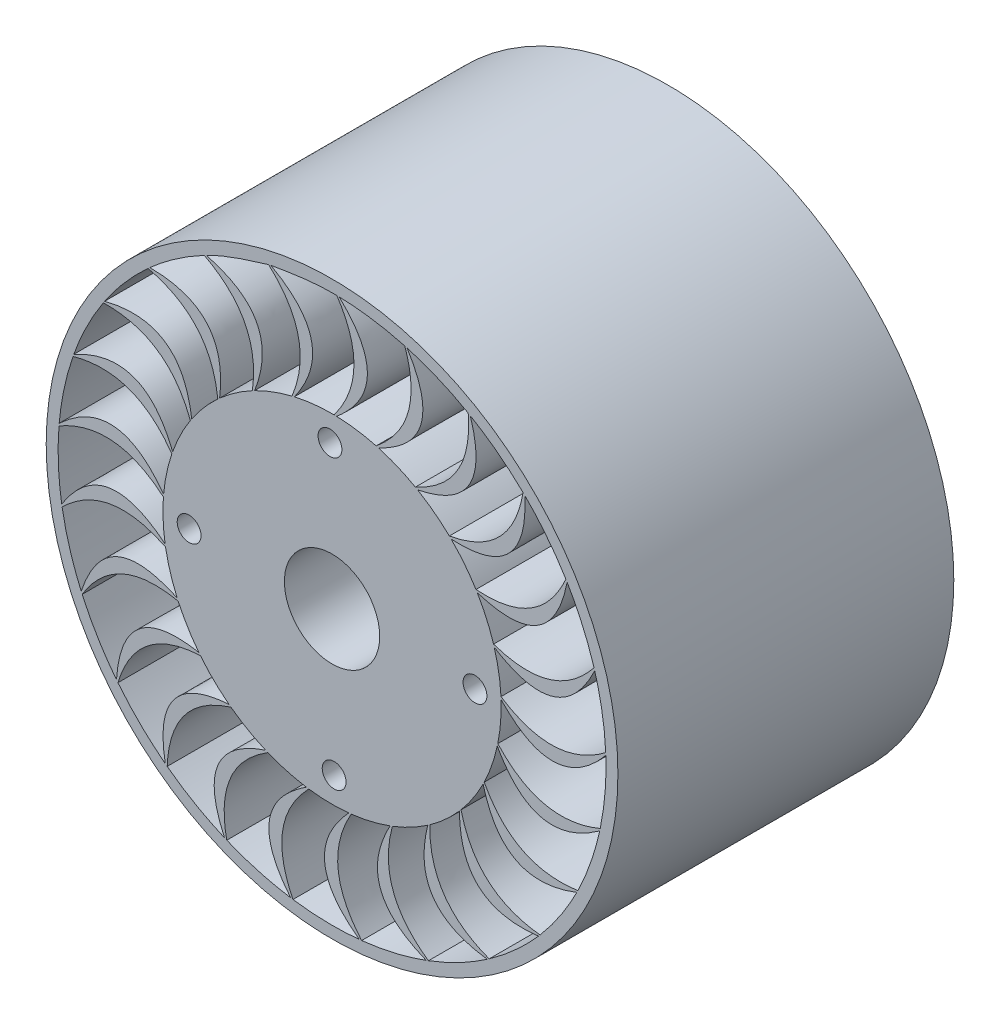
from build123d import *

# Parameters (mm, degrees)
SKETCH1_R           = 70
SKETCH1_R_2         = 50
BOSS_EXTRUDE1_DEPTH = 30
SKETCH2_R           = 70
SKETCH2_R_2         = 34
BOSS_EXTRUDE2_DEPTH = 81
SKETCH3_R           = 70
SKETCH3_R_2         = 20
BOSS_EXTRUDE3_DEPTH = 30
SKETCH5_R           = 120
SKETCH5_R_2         = 70
BOSS_EXTRUDE4_DEPTH = 141
SKETCH6_R           = 5
CUT_EXTRUDE1_DEPTH  = 142.0000001


with BuildPart() as part:
    # Sketch1 → Boss-Extrude1 (new body)
    with BuildSketch(Plane.XY):
        Circle(SKETCH1_R)
        Circle(SKETCH1_R_2, mode=Mode.SUBTRACT)
    extrude(amount=BOSS_EXTRUDE1_DEPTH)

    # Sketch2 → Boss-Extrude2 (add)
    with BuildSketch(Plane.XY.offset(30)):
        Circle(SKETCH2_R)
        Circle(SKETCH2_R_2, mode=Mode.SUBTRACT)
    extrude(amount=BOSS_EXTRUDE2_DEPTH)

    # Sketch3 → Boss-Extrude3 (add)
    with BuildSketch(Plane.XY.offset(111)):
        Circle(SKETCH3_R)
        Circle(SKETCH3_R_2, mode=Mode.SUBTRACT)
    extrude(amount=BOSS_EXTRUDE3_DEPTH)

    # Sketch5 → Boss-Extrude4 (add)
    with BuildSketch(Plane.XY.offset(141)):
        Circle(SKETCH5_R)
        Circle(SKETCH5_R_2, mode=Mode.SUBTRACT)
        with BuildLine():
            add(Edge.make_bspline(
                [(3.010356442, 114.960592179), (27.186039346, 92.132028613), (1.880486429, 70.975092609)],
                knots=[0, 0, 0, 1, 1, 1], degree=2))
            add(Edge.make_bspline(
                [(1.880486429, 70.975092609), (7.482108789, 70.809428101), (13.106315909, 70.025111339), (18.509578891, 68.548490058)],
                knots=[0.04013797, 0.04013797, 0.04013797, 0.04013797, 0.078021655, 0.078021655, 0.078021655, 0.078021655], degree=3))
            add(Edge.make_bspline(
                [(30.542982673, 110.872116465), (39.387805802, 85.35679232), (18.509578891, 68.548490058)],
                knots=[0, 0, 0, 1, 1, 1], degree=2))
            add(Edge.make_bspline(
                [(3.010356442, 114.960592179), (12.287578337, 114.69195374), (21.602560741, 113.35448348), (30.542982673, 110.872116465)],
                knots=[0.040055567, 0.040055567, 0.040055567, 0.040055567, 0.07872198, 0.07872198, 0.07872198, 0.07872198], degree=3))
        make_face(mode=Mode.SUBTRACT)
        with BuildLine():
            add(Edge.make_bspline(
                [(2.010644574, 114.984595961), (16.922994403, 92.47050071), (0.880750175, 70.998058277)],
                knots=[0, 0, 0, 1, 1, 1], degree=2))
            add(Edge.make_bspline(
                [(-15.829380282, 69.212937518), (-7.517567155, 71.135198843), (0.880750175, 70.998058277)],
                knots=[0, 0, 0, 0.037883687, 0.037883687, 0.037883687], degree=2))
            add(Edge.make_bspline(
                [(-25.673756139, 112.097538982), (3.419636128, 95.998424573), (-15.829380282, 69.212937518)],
                knots=[0, 0, 0, 1, 1, 1], degree=2))
            add(Edge.make_bspline(
                [(-25.673756139, 112.097538982), (-16.468268012, 113.6256958), (-7.262779885, 115.153852619), (2.010644574, 114.984595961)],
                knots=[0, 0, 0, 0, 0.038666414, 0.038666414, 0.038666414, 0.038666414], degree=3))
        make_face(mode=Mode.SUBTRACT)
        with BuildLine():
            add(Edge.make_bspline(
                [(31.505317256, 110.600248574), (49.244243728, 82.476638458), (19.472195263, 68.277621602)],
                knots=[0, 0, 0, 1, 1, 1], degree=2))
            add(Edge.make_bspline(
                [(19.472195263, 68.277621602), (24.856925464, 66.724358238), (30.109025893, 64.5670177), (34.975382691, 61.791768106)],
                knots=[0.027314642, 0.027314642, 0.027314642, 0.027314642, 0.486342697, 0.486342697, 0.486342697, 0.486342697], degree=3))
            add(Edge.make_bspline(
                [(57.156192841, 99.793134132), (59.377736504, 72.879802749), (34.975382691, 61.791768106)],
                knots=[0, 0, 0, 1, 1, 1], degree=2))
            add(Edge.make_bspline(
                [(31.505317256, 110.600248574), (40.42406203, 108.038799553), (49.113985563, 104.421038961), (57.156192841, 99.793134132)],
                knots=[0.080111133, 0.080111133, 0.080111133, 0.080111133, 0.118777546, 0.118777546, 0.118777546, 0.118777546], degree=3))
        make_face(mode=Mode.SUBTRACT)
        with BuildLine():
            add(Edge.make_bspline(
                [(58.020683118, 99.290484592), (68.208251169, 67.638937781), (35.840394454, 61.290016523)],
                knots=[0, 0, 0, 1, 1, 1], degree=2))
            add(Edge.make_bspline(
                [(35.840394454, 61.290016523), (40.667339603, 58.445243533), (45.217702636, 55.050026808), (49.243554567, 51.152442108)],
                knots=[0.513657329, 0.513657329, 0.513657329, 0.513657329, 0.972685383, 0.972685383, 0.972685383, 0.972685383], degree=3))
            add(Edge.make_bspline(
                [(80.178069207, 82.443782168), (75.636745646, 55.823507137), (49.243554567, 51.152442108)],
                knots=[0, 0, 0, 1, 1, 1], degree=2))
            add(Edge.make_bspline(
                [(58.020683118, 99.290484592), (66.022220381, 94.591570991), (73.539435738, 88.926309934), (80.178069207, 82.443782168)],
                knots=[0.120166699, 0.120166699, 0.120166699, 0.120166699, 0.158833112, 0.158833112, 0.158833112, 0.158833112], degree=3))
        make_face(mode=Mode.SUBTRACT)
        with BuildLine():
            add(Edge.make_bspline(
                [(80.890396075, 81.741934298), (82.886483337, 48.551233884), (49.95660985, 50.451334297)],
                knots=[0, 0, 0, 1, 1, 1], degree=2))
            add(Edge.make_bspline(
                [(49.95660985, 50.451334297), (53.924021721, 46.495976763), (57.490074061, 42.075360103), (60.417572803, 37.299020048)],
                knots=[0.159954411, 0.159954411, 0.159954411, 0.159954411, 0.197838097, 0.197838097, 0.197838097, 0.197838097], degree=3))
            add(Edge.make_bspline(
                [(98.162062611, 59.914184164), (87.143219886, 35.259615268), (60.417572803, 37.299020048)],
                knots=[0, 0, 0, 1, 1, 1], degree=2))
            add(Edge.make_bspline(
                [(80.890396075, 81.741934298), (87.471978013, 75.200745013), (93.344133117, 67.844012423), (98.162062611, 59.914184164)],
                knots=[0.160222265, 0.160222265, 0.160222265, 0.160222265, 0.198888678, 0.198888678, 0.198888678, 0.198888678], degree=3))
        make_face(mode=Mode.SUBTRACT)
        with BuildLine():
            add(Edge.make_bspline(
                [(98.677467953, 59.057237647), (92.356652922, 26.412877403), (60.933867721, 36.44260919)],
                knots=[0, 0, 0, 1, 1, 1], degree=2))
            add(Edge.make_bspline(
                [(60.933867721, 36.44260919), (63.793312468, 31.624291819), (66.147646288, 26.456264684), (67.795332741, 21.101963382)],
                knots=[0.20009238, 0.20009238, 0.20009238, 0.20009238, 0.237976065, 0.237976065, 0.237976065, 0.237976065], degree=3))
            add(Edge.make_bspline(
                [(109.978172606, 33.619957619), (93.174165131, 12.480232096), (67.795332741, 21.101963382)],
                knots=[0, 0, 0, 1, 1, 1], degree=2))
            add(Edge.make_bspline(
                [(98.677467953, 59.057237647), (103.425549766, 51.084778989), (107.283675322, 42.498826084), (109.978172606, 33.619957619)],
                knots=[0.200277831, 0.200277831, 0.200277831, 0.200277831, 0.238944244, 0.238944244, 0.238944244, 0.238944244], degree=3))
        make_face(mode=Mode.SUBTRACT)
        with BuildLine():
            add(Edge.make_bspline(
                [(110.264271608, 32.661757556), (96.02371434, 2.614902696), (68.082426584, 20.144060921)],
                knots=[0, 0, 0, 1, 1, 1], degree=2))
            add(Edge.make_bspline(
                [(68.082426584, 20.144060921), (69.653775512, 14.765995138), (70.648902028, 9.174841436), (70.913262588, 3.578992749)],
                knots=[0.240230348, 0.240230348, 0.240230348, 0.240230348, 0.278114034, 0.278114034, 0.278114034, 0.278114034], degree=3))
            add(Edge.make_bspline(
                [(114.883949544, 5.213265492), (93.35063491, -11.083329958), (70.913262588, 3.578992749)],
                knots=[0, 0, 0, 1, 1, 1], degree=2))
            add(Edge.make_bspline(
                [(110.264271608, 32.661757556), (112.880513856, 23.758968418), (114.482189644, 14.483282202), (114.883949544, 5.213265492)],
                knots=[0.240333397, 0.240333397, 0.240333397, 0.240333397, 0.278999811, 0.278999811, 0.278999811, 0.278999811], degree=3))
        make_face(mode=Mode.SUBTRACT)
        with BuildLine():
            add(Edge.make_bspline(
                [(114.922765555, 4.214019117), (93.657252635, -21.347375965), (70.953116196, 2.579787219)],
                knots=[0, 0, 0, 1, 1, 1], degree=2))
            add(Edge.make_bspline(
                [(70.953116196, 2.579787219), (71.137627832, -3.020095492), (70.711027141, -8.683070558), (69.575451347, -14.168859161)],
                knots=[0.280368316, 0.280368316, 0.280368316, 0.280368316, 0.318252002, 0.318252002, 0.318252002, 0.318252002], degree=3))
            add(Edge.make_bspline(
                [(112.57114542, -23.520995279), (87.661540978, -33.950485629), (69.575451347, -14.168859161)],
                knots=[0, 0, 0, 1, 1, 1], degree=2))
            add(Edge.make_bspline(
                [(114.922765555, 4.214019117), (115.242780116, -5.059705519), (114.487366955, -14.442299566), (112.57114542, -23.520995279)],
                knots=[0.280388964, 0.280388964, 0.280388964, 0.280388964, 0.319055377, 0.319055377, 0.319055377, 0.319055377], degree=3))
        make_face(mode=Mode.SUBTRACT)
        with BuildLine():
            add(Edge.make_bspline(
                [(112.360239486, -24.498501641), (85.405961299, -43.968320484), (69.365560569, -15.146584001)],
                knots=[0, 0, 0, 1, 1, 1], degree=2))
            add(Edge.make_bspline(
                [(69.365560569, -15.146584001), (68.151641236, -20.61642228), (66.330118358, -25.995393291), (63.865958616, -31.026429541)],
                knots=[0.320506285, 0.320506285, 0.320506285, 0.320506285, 0.35838997, 0.35838997, 0.35838997, 0.35838997], degree=3))
            add(Edge.make_bspline(
                [(103.18508222, -50.777345413), (76.464350029, -54.684407427), (63.865958616, -31.026429541)],
                knots=[0, 0, 0, 1, 1, 1], degree=2))
            add(Edge.make_bspline(
                [(112.360239486, -24.498501641), (110.363918667, -33.560459549), (107.298881945, -42.460418538), (103.18508222, -50.777345413)],
                knots=[0.32044453, 0.32044453, 0.32044453, 0.32044453, 0.359110943, 0.359110943, 0.359110943, 0.359110943], degree=3))
        make_face(mode=Mode.SUBTRACT)
        with BuildLine():
            add(Edge.make_bspline(
                [(102.737706338, -51.671691442), (71.788299315, -63.826573723), (63.419511664, -31.921239643)],
                knots=[0, 0, 0, 1, 1, 1], degree=2))
            add(Edge.make_bspline(
                [(63.419511664, -31.921239643), (60.883436374, -36.917343432), (57.781444292, -41.674329859), (54.143532823, -45.934495245)],
                knots=[0.360644253, 0.360644253, 0.360644253, 0.360644253, 0.398527939, 0.398527939, 0.398527939, 0.398527939], degree=3))
            add(Edge.make_bspline(
                [(87.315520817, -74.843168188), (60.462622752, -71.982306791), (54.143532823, -45.934495245)],
                knots=[0, 0, 0, 1, 1, 1], degree=2))
            add(Edge.make_bspline(
                [(102.737706338, -51.671691442), (98.550486319, -59.95248648), (93.368413565, -67.810593254), (87.315520817, -74.843168188)],
                knots=[0.360500096, 0.360500096, 0.360500096, 0.360500096, 0.399166509, 0.399166509, 0.399166509, 0.399166509], degree=3))
        make_face(mode=Mode.SUBTRACT)
        with BuildLine():
            add(Edge.make_bspline(
                [(86.659785257, -75.598158834), (53.659914465, -79.674368597), (53.4885816, -46.6901664)],
                knots=[0, 0, 0, 1, 1, 1], degree=2))
            add(Edge.make_bspline(
                [(53.4885816, -46.6901664), (49.789701291, -50.898612124), (45.602149577, -54.734715014), (41.019069737, -57.956327678)],
                knots=[0.400782221, 0.400782221, 0.400782221, 0.400782221, 0.438665907, 0.438665907, 0.438665907, 0.438665907], degree=3))
            add(Edge.make_bspline(
                [(65.959604117, -94.206319452), (40.661806522, -84.757293087), (41.019069737, -57.956327678)],
                knots=[0, 0, 0, 1, 1, 1], degree=2))
            add(Edge.make_bspline(
                [(86.659785257, -75.598158834), (80.544764471, -82.577478195), (73.571264376, -88.899979006), (65.959604117, -94.206319452)],
                knots=[0.400555662, 0.400555662, 0.400555662, 0.400555662, 0.439222075, 0.439222075, 0.439222075, 0.439222075], degree=3))
        make_face(mode=Mode.SUBTRACT)
        with BuildLine():
            add(Edge.make_bspline(
                [(65.136711157, -94.774515877), (32.159879842, -90.51592987), (40.196767236, -58.525378288)],
                knots=[0, 0, 0, 1, 1, 1], degree=2))
            add(Edge.make_bspline(
                [(40.196767236, -58.525378288), (35.567496163, -61.681733823), (30.557504091, -64.355916724), (25.317227642, -66.336550894)],
                knots=[0.44092019, 0.44092019, 0.44092019, 0.44092019, 0.478803876, 0.478803876, 0.478803876, 0.478803876], degree=3))
            add(Edge.make_bspline(
                [(40.459202907, -107.650141199), (18.306059444, -92.206666943), (25.317227642, -66.336550894)],
                knots=[0, 0, 0, 1, 1, 1], degree=2))
            add(Edge.make_bspline(
                [(65.136711157, -94.774515877), (57.478118849, -100.013823256), (49.151362069, -104.403452126), (40.459202907, -107.650141199)],
                knots=[0.440611228, 0.440611228, 0.440611228, 0.440611228, 0.479277641, 0.479277641, 0.479277641, 0.479277641], degree=3))
        make_face(mode=Mode.SUBTRACT)
        with BuildLine():
            add(Edge.make_bspline(
                [(39.520857939, -107.99584153), (8.639121693, -95.670042375), (24.379242154, -66.683225417)],
                knots=[0, 0, 0, 1, 1, 1], degree=2))
            add(Edge.make_bspline(
                [(24.379242154, -66.683225417), (19.110454442, -68.589165338), (13.592818241, -69.933399496), (8.024611024, -70.548604649)],
                knots=[0.481058158, 0.481058158, 0.481058158, 0.481058158, 0.518941844, 0.518941844, 0.518941844, 0.518941844], degree=3))
            add(Edge.make_bspline(
                [(12.416601181, -114.329908664), (-5.199924674, -93.862356802), (8.024611024, -70.548604649)],
                knots=[0, 0, 0, 1, 1, 1], degree=2))
            add(Edge.make_bspline(
                [(39.520857939, -107.99584153), (30.799911632, -111.165931976), (21.643098918, -113.34687238), (12.416601181, -114.329908664)],
                knots=[0.480666794, 0.480666794, 0.480666794, 0.480666794, 0.519333207, 0.519333207, 0.519333207, 0.519333207], degree=3))
        make_face(mode=Mode.SUBTRACT)
        with BuildLine():
            add(Edge.make_bspline(
                [(11.421763868, -114.431391279), (-15.424464244, -94.812854268), (7.029879627, -70.651120249)],
                knots=[0, 0, 0, 1, 1, 1], degree=2))
            add(Edge.make_bspline(
                [(7.029879627, -70.651120249), (1.452632586, -71.186887328), (-4.225954335, -71.11670922), (-9.772221418, -70.327830114)],
                knots=[0.521196127, 0.521196127, 0.521196127, 0.521196127, 0.559079812, 0.559079812, 0.559079812, 0.559079812], degree=3))
            add(Edge.make_bspline(
                [(-16.406181263, -113.825907492), (-28.3791784, -89.620329582), (-9.772221418, -70.327830114)],
                knots=[0, 0, 0, 1, 1, 1], degree=2))
            add(Edge.make_bspline(
                [(11.421763868, -114.431391279), (2.18643269, -115.333076352), (-7.225079736, -115.168291782), (-16.406181263, -113.825907492)],
                knots=[0.52072236, 0.52072236, 0.52072236, 0.52072236, 0.559388773, 0.559388773, 0.559388773, 0.559388773], degree=3))
        make_face(mode=Mode.SUBTRACT)
        with BuildLine():
            add(Edge.make_bspline(
                [(-17.395001632, -113.676795865), (-38.518874366, -87.99822583), (-10.761196091, -70.179745359)],
                knots=[0, 0, 0, 1, 1, 1], degree=2))
            add(Edge.make_bspline(
                [(-10.761196091, -70.179745359), (-16.296463442, -69.311674615), (-21.779192573, -67.831473417), (-26.955029248, -65.688099366)],
                knots=[0.561334095, 0.561334095, 0.561334095, 0.561334095, 0.599217781, 0.599217781, 0.599217781, 0.599217781], degree=3))
            add(Edge.make_bspline(
                [(-44.198103, -106.16980593), (-49.775263977, -79.747127454), (-26.955029248, -65.688099366)],
                knots=[0, 0, 0, 1, 1, 1], degree=2))
            add(Edge.make_bspline(
                [(-17.395001632, -113.676795865), (-26.564427858, -112.253419375), (-35.639280059, -109.753263851), (-44.198103, -106.16980593)],
                knots=[0.560777926, 0.560777926, 0.560777926, 0.560777926, 0.599444339, 0.599444339, 0.599444339, 0.599444339], degree=3))
        make_face(mode=Mode.SUBTRACT)
        with BuildLine():
            add(Edge.make_bspline(
                [(-45.118775206, -105.779469293), (-59.193001949, -75.654345228), (-27.876106282, -65.298718965)],
                knots=[0, 0, 0, 1, 1, 1], degree=2))
            add(Edge.make_bspline(
                [(-27.876106282, -65.298718965), (-33.021588323, -63.081309732), (-37.963841938, -60.282898486), (-42.444153456, -56.92094375)],
                knots=[0.601472063, 0.601472063, 0.601472063, 0.601472063, 0.639355749, 0.639355749, 0.639355749, 0.639355749], degree=3))
            add(Edge.make_bspline(
                [(-69.212895377, -91.842664996), (-68.043786657, -64.863120018), (-42.444153456, -56.92094375)],
                knots=[0, 0, 0, 1, 1, 1], degree=2))
            add(Edge.make_bspline(
                [(-45.118775206, -105.779469293), (-53.646147707, -102.120467219), (-61.814133343, -97.442034709), (-69.212895377, -91.842664996)],
                knots=[0.600833492, 0.600833492, 0.600833492, 0.600833492, 0.639499906, 0.639499906, 0.639499906, 0.639499906], degree=3))
        make_face(mode=Mode.SUBTRACT)
        with BuildLine():
            add(Edge.make_bspline(
                [(-70.007570198, -91.235629635), (-76.147815523, -58.556823879), (-43.239458195, -56.314733907)],
                knots=[0, 0, 0, 1, 1, 1], degree=2))
            add(Edge.make_bspline(
                [(-55.266355405, -44.577235898), (-50.014169334, -51.135918155), (-43.239458195, -56.314733907)],
                knots=[0.514446505, 0.514446505, 0.514446505, 1, 1, 1], degree=2))
            add(Edge.make_bspline(
                [(-89.87878699, -71.744711647), (-82.036867973, -45.903524202), (-55.266355405, -44.577235898)],
                knots=[0, 0, 0, 1, 1, 1], degree=2))
            add(Edge.make_bspline(
                [(-70.007570198, -91.235629635), (-77.357082798, -85.570910535), (-84.104977292, -79.008164159), (-89.87878699, -71.744711647)],
                knots=[0.640889058, 0.640889058, 0.640889058, 0.640889058, 0.679555472, 0.679555472, 0.679555472, 0.679555472], degree=3))
        make_face(mode=Mode.SUBTRACT)
        with BuildLine():
            add(Edge.make_bspline(
                [(-90.497532085, -70.959119827), (-88.317981795, -37.779961928), (-55.885915925, -43.792287007)],
                knots=[0, 0, 0, 1, 1, 1], degree=2))
            add(Edge.make_bspline(
                [(-64.615968987, -29.432576371), (-61.045520812, -37.159968997), (-55.885915925, -43.792287007)],
                knots=[0, 0, 0, 0.485553468, 0.485553468, 0.485553468], degree=2))
            add(Edge.make_bspline(
                [(-104.897263865, -47.138774206), (-90.875271165, -24.059641139), (-64.615968987, -29.432576371)],
                knots=[0, 0, 0, 1, 1, 1], degree=2))
            add(Edge.make_bspline(
                [(-90.497532085, -70.959119827), (-96.207387878, -63.644618834), (-101.111196202, -55.609920083), (-104.897263865, -47.138774206)],
                knots=[0.680944625, 0.680944625, 0.680944625, 0.680944625, 0.719611038, 0.719611038, 0.719611038, 0.719611038], degree=3))
        make_face(mode=Mode.SUBTRACT)
        with BuildLine():
            add(Edge.make_bspline(
                [(-105.301201204, -46.22398755), (-94.938804461, -14.629246024), (-65.020856023, -28.518209656)],
                knots=[0, 0, 0, 1, 1, 1], degree=2))
            add(Edge.make_bspline(
                [(-65.020856023, -28.518209656), (-67.253597792, -23.380109311), (-68.941892141, -17.957172655), (-69.905523598, -12.438559825)],
                knots=[0.721288505, 0.721288505, 0.721288505, 0.721288505, 0.759172191, 0.759172191, 0.759172191, 0.759172191], degree=3))
            add(Edge.make_bspline(
                [(-113.324659866, -19.570934218), (-94.003646853, -0.704002338), (-69.905523598, -12.438559825)],
                knots=[0, 0, 0, 1, 1, 1], degree=2))
            add(Edge.make_bspline(
                [(-105.301201204, -46.22398755), (-109.012628952, -37.719301662), (-111.764226794, -28.717500209), (-113.324659866, -19.570934218)],
                knots=[0.721000191, 0.721000191, 0.721000191, 0.721000191, 0.759666604, 0.759666604, 0.759666604, 0.759666604], degree=3))
        make_face(mode=Mode.SUBTRACT)
        with BuildLine():
            add(Edge.make_bspline(
                [(-113.488408581, -18.584432135), (-95.594272881, 9.44067921), (-70.070296608, -11.452228311)],
                knots=[0, 0, 0, 1, 1, 1], degree=2))
            add(Edge.make_bspline(
                [(-70.070296608, -11.452228311), (-70.955200165, -5.919638296), (-71.241726718, -0.247840107), (-70.802657066, 5.337017181)],
                knots=[0.761426473, 0.761426473, 0.761426473, 0.761426473, 0.799310159, 0.799310159, 0.799310159, 0.799310159], degree=3))
            add(Edge.make_bspline(
                [(-114.63145071, 9.226619545), (-91.225427689, 22.695871519), (-70.802657066, 5.337017181)],
                knots=[0, 0, 0, 1, 1, 1], degree=2))
            add(Edge.make_bspline(
                [(-113.488408581, -18.584432135), (-114.968205627, -9.423942047), (-115.394699976, -0.020654183), (-114.63145071, 9.226619545)],
                knots=[0.761055757, 0.761055757, 0.761055757, 0.761055757, 0.79972217, 0.79972217, 0.79972217, 0.79972217], degree=3))
        make_face(mode=Mode.SUBTRACT)
        with BuildLine():
            add(Edge.make_bspline(
                [(-114.544721865, 10.222851499), (-90.243201566, 32.917411849), (-70.716962756, 6.333338658)],
                knots=[0, 0, 0, 1, 1, 1], degree=2))
            add(Edge.make_bspline(
                [(-70.716962756, 6.333338658), (-70.19816798, 11.912189884), (-69.06517226, 17.477043617), (-67.250999197, 22.777249769)],
                knots=[0.801564442, 0.801564442, 0.801564442, 0.801564442, 0.839448127, 0.839448127, 0.839448127, 0.839448127], degree=3))
            add(Edge.make_bspline(
                [(-108.73552592, 37.444430867), (-82.715179399, 44.669680299), (-67.250999197, 22.777249769)],
                knots=[0, 0, 0, 1, 1, 1], degree=2))
            add(Edge.make_bspline(
                [(-114.544721865, 10.222851499), (-113.69990712, 19.463558506), (-111.774499765, 28.677489615), (-108.73552592, 37.444430867)],
                knots=[0.801111323, 0.801111323, 0.801111323, 0.801111323, 0.839777736, 0.839777736, 0.839777736, 0.839777736], degree=3))
        make_face(mode=Mode.SUBTRACT)
        with BuildLine():
            add(Edge.make_bspline(
                [(-108.403769009, 38.387795777), (-79.221818004, 54.32582244), (-66.920222056, 23.720958666)],
                knots=[0, 0, 0, 1, 1, 1], degree=2))
            add(Edge.make_bspline(
                [(-66.920222056, 23.720958666), (-65.03032232, 28.995521175), (-62.548998918, 34.103779432), (-59.473713716, 38.786303985)],
                knots=[0.84170241, 0.84170241, 0.84170241, 0.84170241, 0.879586096, 0.879586096, 0.879586096, 0.879586096], degree=3))
            add(Edge.make_bspline(
                [(-96.007348135, 63.309470888), (-69.007632182, 63.836728782), (-59.473713716, 38.786303985)],
                knots=[0, 0, 0, 1, 1, 1], degree=2))
            add(Edge.make_bspline(
                [(-108.403769009, 38.387795777), (-105.287425286, 47.12809208), (-101.131096514, 55.573720511), (-96.007348135, 63.309470888)],
                knots=[0.841166889, 0.841166889, 0.841166889, 0.841166889, 0.879833302, 0.879833302, 0.879833302, 0.879833302], degree=3))
        make_face(mode=Mode.SUBTRACT)
        with BuildLine():
            add(Edge.make_bspline(
                [(-95.451408665, 64.140693666), (-63.22263626, 72.32074181), (-58.918637688, 39.618103602)],
                knots=[0, 0, 0, 1, 1, 1], degree=2))
            add(Edge.make_bspline(
                [(-58.918637688, 39.618103602), (-55.776382381, 44.256955761), (-52.102645004, 48.587613418), (-47.959476074, 52.358272075)],
                knots=[0.881840378, 0.881840378, 0.881840378, 0.881840378, 0.919724064, 0.919724064, 0.919724064, 0.919724064], degree=3))
            add(Edge.make_bspline(
                [(-77.246675576, 85.196544017), (-50.964081643, 78.992680821), (-47.959476074, 52.358272075)],
                knots=[0, 0, 0, 1, 1, 1], degree=2))
            add(Edge.make_bspline(
                [(-95.451408665, 64.140693666), (-90.259347009, 71.831392729), (-84.133241598, 78.977980553), (-77.246675576, 85.196544017)],
                knots=[0.881222455, 0.881222455, 0.881222455, 0.881222455, 0.919888868, 0.919888868, 0.919888868, 0.919888868], degree=3))
        make_face(mode=Mode.SUBTRACT)
        with BuildLine():
            add(Edge.make_bspline(
                [(-76.501485268, 85.863395878), (-43.250943764, 85.771482995), (-47.214978627, 53.025897383)],
                knots=[0, 0, 0, 1, 1, 1], degree=2))
            add(Edge.make_bspline(
                [(-47.214978627, 53.025897383), (-43.017813707, 56.737486972), (-38.382670228, 60.016403845), (-33.431768167, 62.640377371)],
                knots=[0.921978347, 0.921978347, 0.921978347, 0.921978347, 0.959862032, 0.959862032, 0.959862032, 0.959862032], degree=3))
            add(Edge.make_bspline(
                [(-53.632310298, 101.730404954), (-29.718270422, 89.185232209), (-33.431768167, 62.640377371)],
                knots=[0, 0, 0, 1, 1, 1], degree=2))
            add(Edge.make_bspline(
                [(-76.501485268, 85.863395878), (-69.559915213, 92.021118634), (-61.847800562, 97.41338744), (-53.632310298, 101.730404954)],
                knots=[0.921278021, 0.921278021, 0.921278021, 0.921278021, 0.959944434, 0.959944434, 0.959944434, 0.959944434], degree=3))
        make_face(mode=Mode.SUBTRACT)
        with BuildLine():
            add(Edge.make_bspline(
                [(-52.7446922, 102.190985144), (-20.561635404, 93.832886459), (-32.544628814, 63.101879016)],
                knots=[0, 0, 0, 1, 1, 1], degree=2))
            add(Edge.make_bspline(
                [(-32.544628814, 63.101879016), (-25.062673728, 66.921865687), (-16.803419313, 68.986557382)],
                knots=[0.962116315, 0.962116315, 0.962116315, 1, 1, 1], degree=2))
            add(Edge.make_bspline(
                [(-26.648029718, 111.87217041), (-6.605150973, 93.773947457), (-16.803419313, 68.986557382)],
                knots=[0, 0, 0, 1, 1, 1], degree=2))
            add(Edge.make_bspline(
                [(-52.7446922, 102.190985144), (-44.487323772, 106.415613849), (-35.567676745, 109.143892129), (-26.648029718, 111.87217041)],
                knots=[0.961333587, 0.961333587, 0.961333587, 0.961333587, 1, 1, 1, 1], degree=3))
        make_face(mode=Mode.SUBTRACT)
    extrude(amount=-BOSS_EXTRUDE4_DEPTH)

    # Sketch6 → Cut-Extrude1 (cut, through all)
    with BuildSketch(Plane(origin=(0, 0, 0), x_dir=(-1, 0, 0), z_dir=(0, 0, -1))):
        with Locations((0.867778316, 60)):
            Circle(SKETCH6_R)
        with Locations((60, -0.867778316)):
            Circle(SKETCH6_R)
        with Locations((-0.867778316, -60)):
            Circle(SKETCH6_R)
        with Locations((-60, 0.867778316)):
            Circle(SKETCH6_R)
    extrude(amount=-CUT_EXTRUDE1_DEPTH, mode=Mode.SUBTRACT)


solid = part.part
